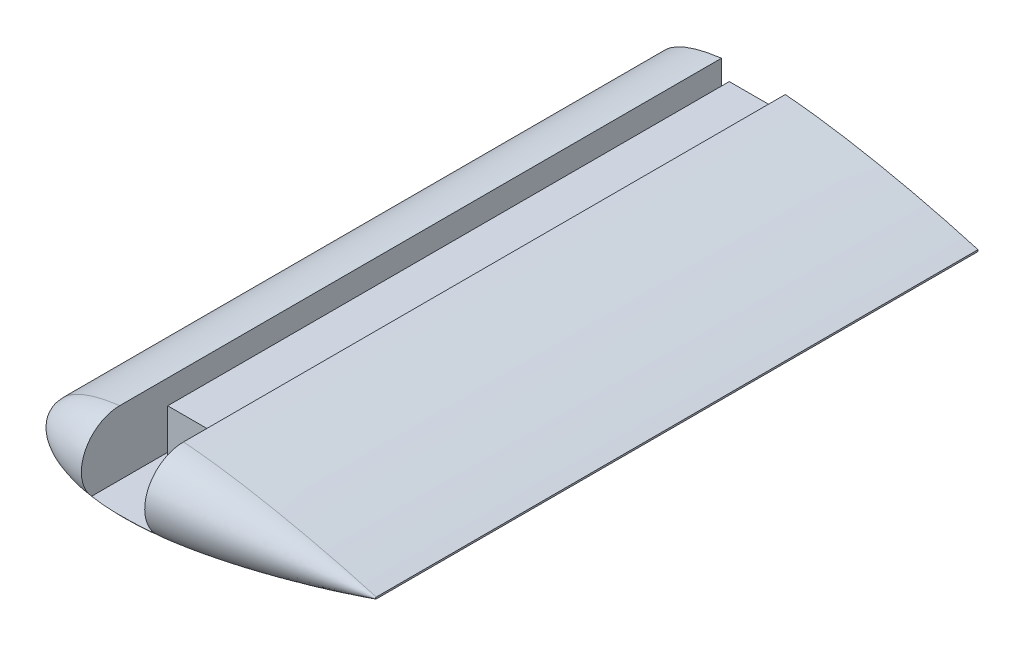
from build123d import *

# Parameters (mm, degrees)
BOSS_EXTRUDE1_DEPTH = 150
REVOLVE1_ANGLE      = 180
CUT_EXTRUDE1_REACH  = 162
CUT_EXTRUDE2_REACH  = 22
SKETCH5_W           = 15.9
SKETCH5_H           = 16.06370057


with BuildPart() as part:
    # Sketch2 → Boss-Extrude1 (new body)
    with BuildSketch(Plane.XY):
        with BuildLine():
            Line((55.998991919, 0.209938863), (55.998991919, -0.209938863))
            add(Edge.make_bspline(
                [(55.998991919, 0.209938863), (53.463896497, 0.950455214), (48.803904258, 2.233873897), (42.428923908, 3.819934884), (36.743376831, 5.120873453), (31.199749362, 6.287249396), (25.282426203, 7.407488419), (20.176484373, 8.245231015), (14.979623954, 8.974887306), (10.821499069, 9.44862332), (6.697350987, 9.777022894), (3.680655604, 9.939622605), (0.739619613, 10.012665726), (-2.107751213, 9.990028944), (-4.843941705, 9.866960982), (-7.452188048, 9.640899897), (-9.916478705, 9.310630744), (-12.221751766, 8.877222993), (-14.354021752, 8.343659433), (-16.300401345, 7.714341159), (-18.049355518, 6.995399514), (-19.590605164, 6.19339349), (-20.915410238, 5.315562027), (-22.015853697, 4.368064829), (-22.884921184, 3.356491652), (-23.514451457, 2.28497611), (-23.895372624, 1.158788991), (-24.018679664, 0), (-23.895372624, -1.158788991), (-23.514451457, -2.28497611), (-22.884921184, -3.356491652), (-22.015853697, -4.368064829), (-20.915410238, -5.315562027), (-19.590605164, -6.19339349), (-18.049355518, -6.995399514), (-16.300401345, -7.714341159), (-14.354021752, -8.343659433), (-12.221751766, -8.877222993), (-9.916478705, -9.310630744), (-7.452188048, -9.640899897), (-4.843941705, -9.866960982), (-2.107751213, -9.990028944), (0.739619613, -10.012665726), (3.680655604, -9.939622605), (7.74070187, -9.72078634), (12.912832982, -9.241334238), (19.136671313, -8.415754469), (25.28242537, -7.407448977), (31.199752667, -6.287252304), (37.517160947, -4.95809922), (44.742570872, -3.275857272), (51.057566095, -1.626260629), (54.945025722, -0.517808616), (55.95791152, -0.221938691), (55.998991919, -0.209938863)],
                knots=[0, 0, 0, 0, 0.046554703, 0.085193372, 0.115793222, 0.149362634, 0.18504799, 0.221946042, 0.240561295, 0.277549679, 0.295701185, 0.31348255, 0.330796889, 0.347551895, 0.363665842, 0.379065349, 0.393686065, 0.407475418, 0.420391934, 0.432405657, 0.443502806, 0.453686421, 0.462984388, 0.471455944, 0.479204465, 0.486388269, 0.493228974, 0.5, 0.506771026, 0.513611731, 0.520795535, 0.528544056, 0.537015612, 0.546313579, 0.556497194, 0.567594343, 0.579608066, 0.592524582, 0.606313935, 0.620934651, 0.636334158, 0.652448105, 0.669203111, 0.68651745, 0.704298815, 0.740866341, 0.778053958, 0.81495201, 0.850637366, 0.884206778, 0.928744289, 0.981399281, 0.999245596, 1, 1, 1, 1], degree=3))
        make_face()
    extrude(amount=BOSS_EXTRUDE1_DEPTH)

    # Sketch4 → Revolve1 (revolve)
    with BuildSketch(Plane.XY.offset(150)):
        with BuildLine():
            Line((55.998991919, 0), (-23.977717827, 0))
            add(Edge.make_bspline(
                [(55.998991919, 0.209938863), (53.463896497, 0.950455214), (48.803904258, 2.233873897), (42.428923908, 3.819934884), (36.743376831, 5.120873453), (31.199749362, 6.287249396), (25.282426203, 7.407488419), (20.176484373, 8.245231015), (14.979623954, 8.974887306), (10.821499069, 9.44862332), (6.697350987, 9.777022894), (3.680655604, 9.939622605), (0.739619613, 10.012665726), (-2.107751213, 9.990028944), (-4.843941705, 9.866960982), (-7.452188048, 9.640899897), (-9.916478705, 9.310630744), (-12.221751766, 8.877222993), (-14.354021752, 8.343659433), (-16.300401345, 7.714341159), (-18.049355518, 6.995399514), (-19.590605164, 6.19339349), (-20.915410238, 5.315562027), (-22.015853697, 4.368064829), (-22.884921184, 3.356491652), (-23.514451457, 2.28497611), (-23.895372624, 1.158788991), (-23.977717827, 0.384942543), (-23.977717827, 0)],
                knots=[0, 0, 0, 0, 0.046554703, 0.085193372, 0.115793222, 0.149362634, 0.18504799, 0.221946042, 0.240561295, 0.277549679, 0.295701185, 0.31348255, 0.330796889, 0.347551895, 0.363665842, 0.379065349, 0.393686065, 0.407475418, 0.420391934, 0.432405657, 0.443502806, 0.453686421, 0.462984388, 0.471455944, 0.479204465, 0.486388269, 0.493228974, 0.5, 0.5, 0.5, 0.5], degree=3))
            Line((55.998991919, 0.209938863), (55.998991919, 0))
        make_face()
    revolve(axis=Axis((55.998991919, 0, 150), (1, 0, 0)), revolution_arc=REVOLVE1_ANGLE)

    # Sketch3 → Cut-Extrude1 (cut, up to next)
    with BuildSketch(Plane(origin=(0, 0, 0), x_dir=(-1, 0, 0), z_dir=(0, 0, -1)), mode=Mode.PRIVATE) as cut_extrude1_sk1:
        with BuildLine():
            Line((6, -6.5), (7.95, -6.5))
            Line((7.95, -6.5), (7.95, 9.56370057))
            add(Edge.make_bspline(
                [(-7.95, 9.673763928), (-7.525333967, 9.706496284), (-6.094337758, 9.809525273), (-3.680655604, 9.939622605), (-0.739619613, 10.012665726), (2.107751213, 9.990028944), (4.843941705, 9.866960982), (6.778071836, 9.69932668), (7.798061571, 9.581867182), (7.95, 9.56370057)],
                knots=[0.28819337, 0.28819337, 0.28819337, 0.28819337, 0.295701185, 0.31348255, 0.330796889, 0.347551895, 0.363665842, 0.379065349, 0.381762425, 0.381762425, 0.381762425, 0.381762425], degree=3))
            Line((-7.95, 9.673763928), (-7.95, -6.5))
            Line((-7.95, -6.5), (-6, -6.5))
            Line((-6, -6.5), (-6, 5.5))
            Line((-6, 5.5), (6, 5.5))
            Line((6, 5.5), (6, -6.5))
        make_face()
    cut_extrude1_tool1 = extrude(cut_extrude1_sk1.sketch, amount=-CUT_EXTRUDE1_REACH, mode=Mode.PRIVATE) & part.part
    add(cut_extrude1_tool1.solids().sort_by_distance((-6.975, -6.270858, 0))[0], mode=Mode.SUBTRACT)

    # Sketch5 → Cut-Extrude2 (cut, up to next)
    with BuildSketch(Plane(origin=(0, 0, 140), x_dir=(-1, 0, 0), z_dir=(0, 0, -1)), mode=Mode.PRIVATE) as cut_extrude2_sk1:
        with Locations((0, 1.531850285)):
            Rectangle(SKETCH5_W, SKETCH5_H)
    cut_extrude2_tool1 = extrude(cut_extrude2_sk1.sketch, amount=-CUT_EXTRUDE2_REACH, mode=Mode.PRIVATE) & part.part
    add(cut_extrude2_tool1.solids().sort_by_distance((0, 1.53185, 140))[0], mode=Mode.SUBTRACT)


solid = part.part
